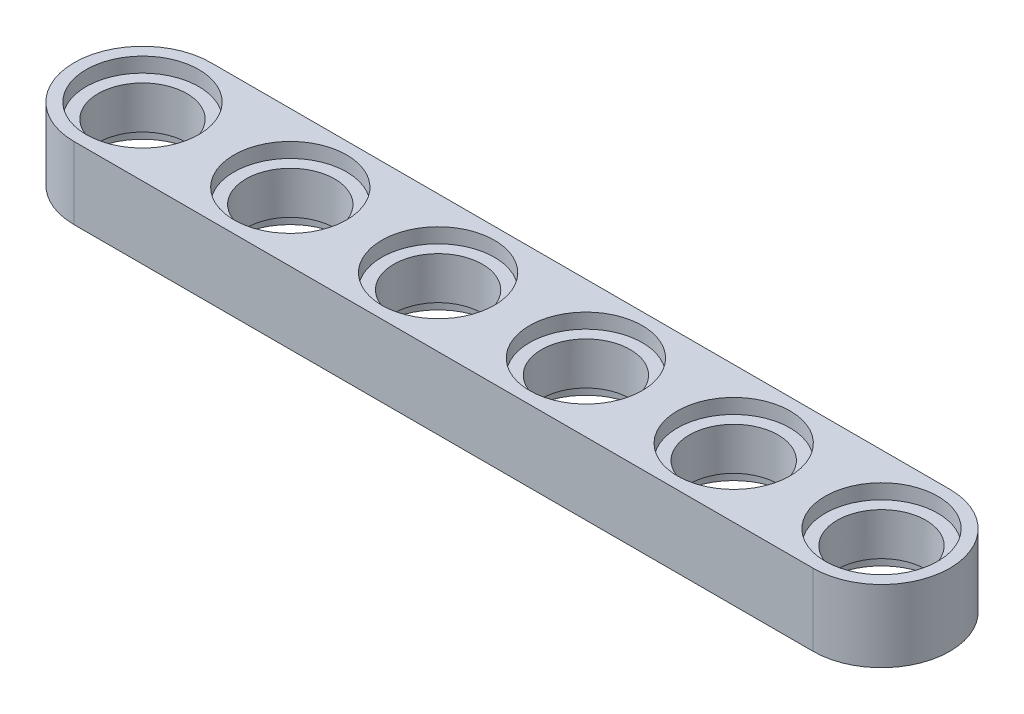
from build123d import *

# Parameters (mm, degrees)
BOSS_EXTRUDE3_DEPTH = 3.9
SKETCH2_R           = 2.4
CUT_EXTRUDE1_DEPTH  = 7.8
SKETCH3_R           = 3.05
CUT_EXTRUDE2_DEPTH  = 0.8
SKETCH4_R           = 3.05
CUT_EXTRUDE3_DEPTH  = 0.8


with BuildPart() as part:
    # Sketch1 → Boss-Extrude3 (new body)
    with BuildSketch(Plane(origin=(0, 0, 0), x_dir=(1, 0, 0), z_dir=(0, 1, 0))):
        with BuildLine():
            Line((-16, -3.7), (24, -3.7))
            ThreePointArc((24, -3.7), (27.7, 0), (24, 3.7))
            Line((24, 3.7), (-16, 3.7))
            ThreePointArc((-16, 3.7), (-19.7, 0), (-16, -3.7))
        make_face()
    extrude(amount=BOSS_EXTRUDE3_DEPTH)

    # Sketch2 → Cut-Extrude1 (cut)
    with BuildSketch(Plane(origin=(0, 3.9, 0), x_dir=(1, 0, 0), z_dir=(0, 1, 0))):
        Circle(SKETCH2_R)
        with Locations((8, 0)):
            Circle(SKETCH2_R)
        with Locations((16, 0)):
            Circle(SKETCH2_R)
        with Locations((-16, 0)):
            Circle(SKETCH2_R)
        with Locations((-8, 0)):
            Circle(SKETCH2_R)
        with Locations((24, 0)):
            Circle(SKETCH2_R)
    extrude(amount=-CUT_EXTRUDE1_DEPTH, mode=Mode.SUBTRACT)

    # Sketch3 → Cut-Extrude2 (cut)
    with BuildSketch(Plane(origin=(0, 3.9, 0), x_dir=(1, 0, 0), z_dir=(0, 1, 0))):
        Circle(SKETCH3_R)
        with Locations((8, 0)):
            Circle(SKETCH3_R)
        with Locations((16, 0)):
            Circle(SKETCH3_R)
        with Locations((-16, 0)):
            Circle(SKETCH3_R)
        with Locations((-8, 0)):
            Circle(SKETCH3_R)
        with Locations((24, 0)):
            Circle(SKETCH3_R)
    extrude(amount=-CUT_EXTRUDE2_DEPTH, mode=Mode.SUBTRACT)

    # Sketch4 → Cut-Extrude3 (cut)
    with BuildSketch(Plane.XZ):
        Circle(SKETCH4_R)
        with Locations((8, 0)):
            Circle(SKETCH4_R)
        with Locations((16, 0)):
            Circle(SKETCH4_R)
        with Locations((-16, 0)):
            Circle(SKETCH4_R)
        with Locations((-8, 0)):
            Circle(SKETCH4_R)
        with Locations((24, 0)):
            Circle(SKETCH4_R)
    extrude(amount=-CUT_EXTRUDE3_DEPTH, mode=Mode.SUBTRACT)


solid = part.part
